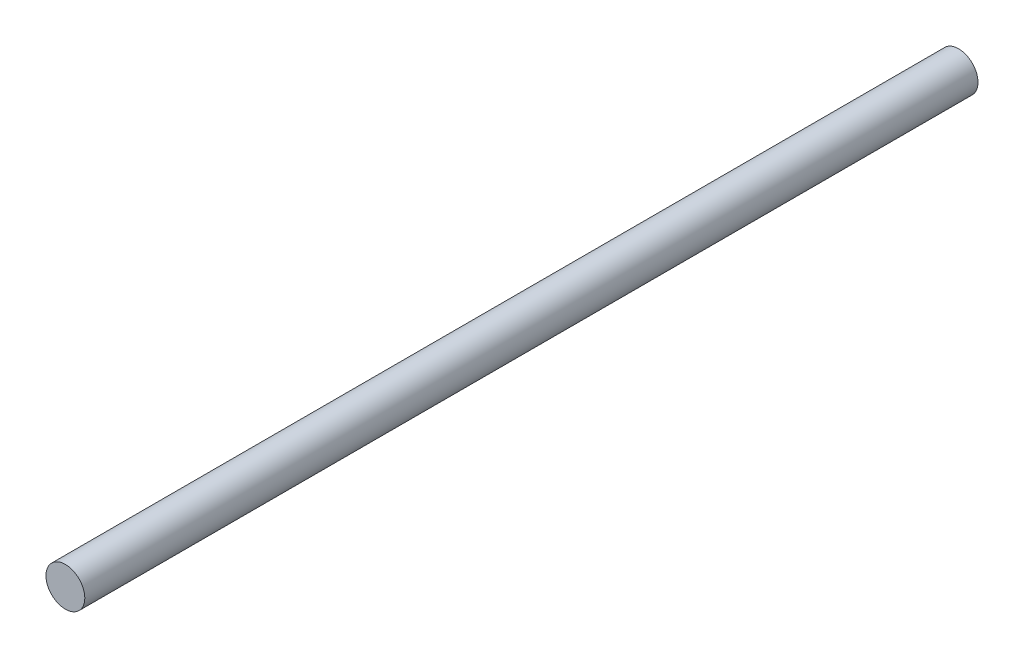
from build123d import *

# Parameters (mm, degrees)
SCHIZZO1_R                   = 5
ESTRUSIONE_ESTRUSIONE1_DEPTH = 230


with BuildPart() as part:
    # Schizzo1 → Estrusione-Estrusione1 (new body)
    with BuildSketch(Plane.XY):
        Circle(SCHIZZO1_R)
    extrude(amount=ESTRUSIONE_ESTRUSIONE1_DEPTH)


solid = part.part
